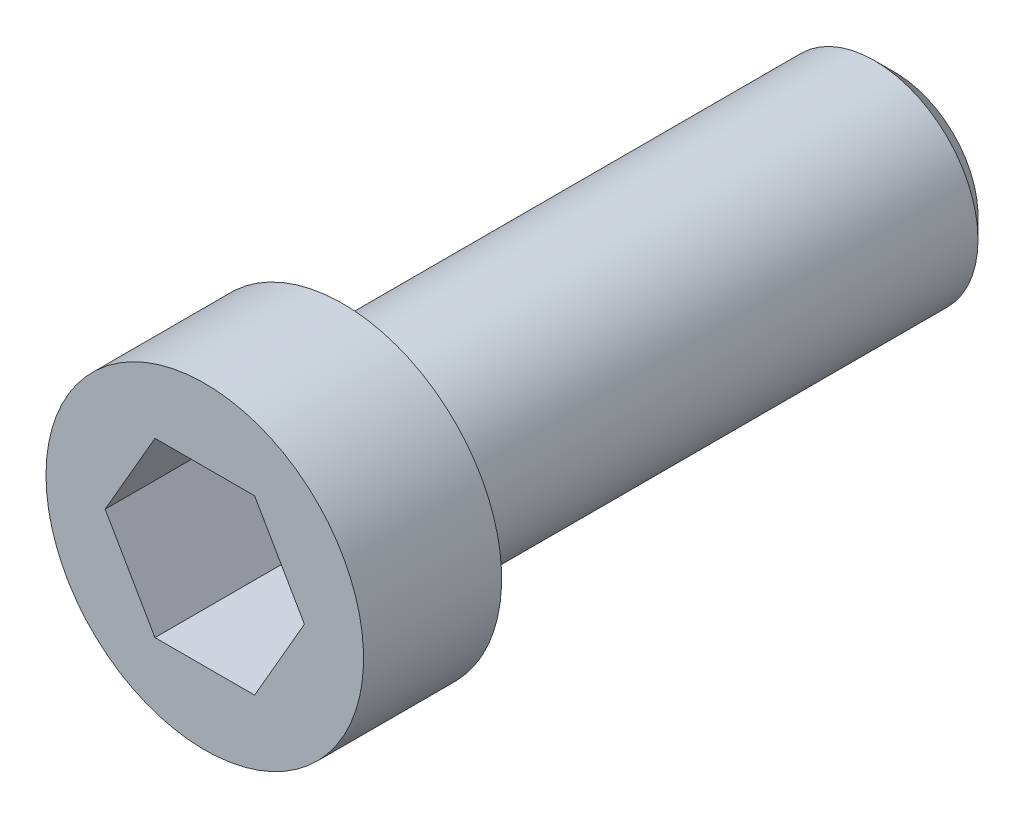
from build123d import *

# Parameters (mm, degrees)
CUT_EXTRUDE_1_DEPTH = 2
FILLET_1_R          = 0.3
CHAMFER_1_SIZE      = 0.3


with BuildPart() as part:
    # Эскиз1 → Повернуть1 (revolve)
    with BuildSketch(Plane(origin=(0, 0, 0), x_dir=(0, 0, -1), z_dir=(1, 0, 0))):
        Polygon((0, 0), (0, 2.3), (2, 2.3), (2, 1.5), (10, 1.5), (10, 0), align=None)
    revolve(axis=Axis((0, 0, 0), (0, 0, 1)))

    # Эскиз2 → Вырез-Вытянуть1 (cut)
    with BuildSketch(Plane.XY):
        Polygon((1.443375673, 0), (0.721687836, 1.25), (-0.721687836, 1.25), (-1.443375673, 0), (-0.721687836, -1.25), (0.721687836, -1.25), align=None)
    extrude(amount=-CUT_EXTRUDE_1_DEPTH, mode=Mode.SUBTRACT)

    # Скругление1
    fillet_1_edges = [part.edges().sort_by_distance(p)[0] for p in [
        (0, -1.5, -2),
    ]]
    fillet(fillet_1_edges, radius=FILLET_1_R)

    # Фаска1
    chamfer_1_edges = [part.edges().sort_by_distance(p)[0] for p in [
        (0, -1.5, -10),
    ]]
    chamfer(chamfer_1_edges, length=CHAMFER_1_SIZE)


solid = part.part
